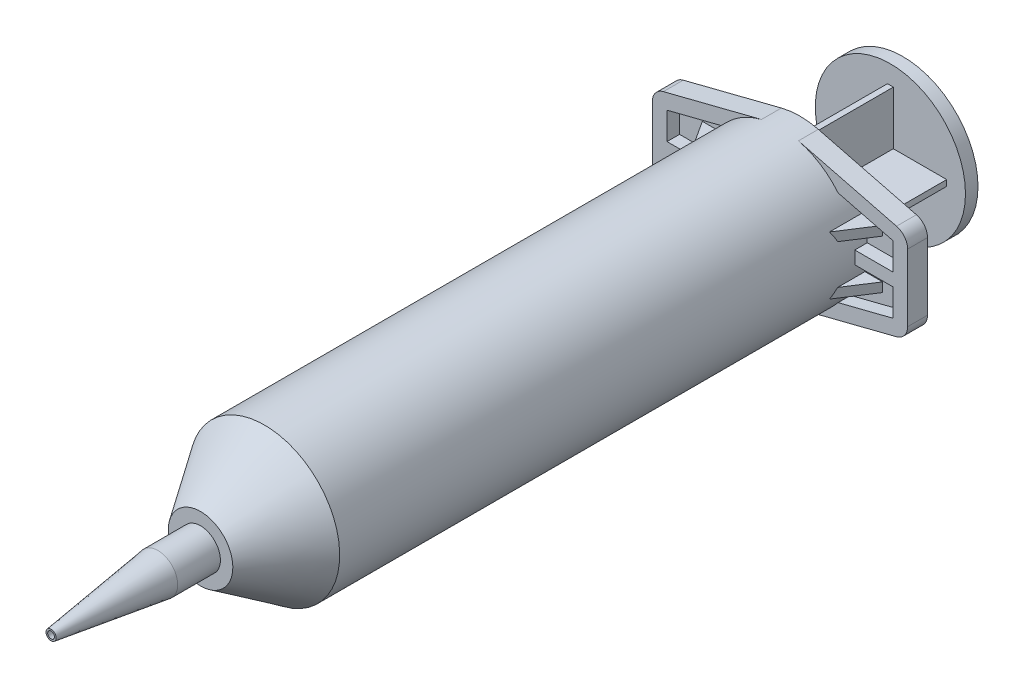
from build123d import *
from build123d.topology import SkipClean

# Parameters (mm, degrees)
BOSS_EXTRUDE1_START = 3.429
SKETCH3_R           = 11.43
BOSS_EXTRUDE1_DEPTH = 3.429
FILLET1_R           = 2.54
SKETCH5_R           = 12.954
BOSS_EXTRUDE2_DEPTH = 2.159
BOSS_EXTRUDE3_DEPTH = 96.8375
SKETCH7_R           = 10.287
BOSS_EXTRUDE4_DEPTH = 1.27
CUT_EXTRUDE1_START  = -2.159
CUT_EXTRUDE1_DEPTH  = 2.159
BOSS_EXTRUDE5_DEPTH = 5.0165
CUT_EXTRUDE2_DEPTH  = 131.416111398
CUT_EXTRUDE3_DEPTH  = 129.299644159


with BuildPart() as part:
    # Sketch2 → Revolve1 (revolve)
    with BuildSketch(Plane(origin=(0, 0, 0), x_dir=(0, 0, -1), z_dir=(1, 0, 0)), mode=Mode.PRIVATE) as revolve1_sk:
        Polygon((52.2605, 11.43), (-36.6395, 11.43), (-46.280429208, 4.987199723), (-46.280429208, 3.1369), (-55.0545, 3.1369), (-73.4695, 0.5842), (-73.4695, 0.8763), (-55.0545, 3.429), (-47.6885, 3.429), (-47.6885, 5.57022), (-36.6395, 12.954), (52.2605, 12.954), align=None)
    revolve(revolve1_sk.sketch.rotate(Axis((0, 0, 73.4695), (0, 0, -1)), 180), axis=Axis((0, 0, 73.4695), (0, 0, -1)))

    # Sketch3 → Boss-Extrude1 (add)
    with BuildSketch(Plane(origin=(0, 0, -52.2605), x_dir=(-1, 0, 0), z_dir=(0, 0, -1)).offset(BOSS_EXTRUDE1_START)):
        with BuildLine():
            Line((-3.188676923, 12.555415385), (-22.0218, 7.7724))
            Line((-22.0218, 7.7724), (-22.0218, -7.7724))
            Line((-22.0218, -7.7724), (-3.188676923, -12.555415385))
            ThreePointArc((-3.188676923, -12.555415385), (0, -12.954), (3.188676923, -12.555415385))
            Line((3.188676923, -12.555415385), (22.0218, -7.7724))
            Line((22.0218, -7.7724), (22.0218, 7.7724))
            Line((22.0218, 7.7724), (3.188676923, 12.555415385))
            ThreePointArc((3.188676923, 12.555415385), (0, 12.954), (-3.188676923, 12.555415385))
        make_face()
        with Locations(Location((0, 0, 0), (0, 0, 270))):
            Circle(SKETCH3_R, mode=Mode.SUBTRACT)
    extrude(amount=-BOSS_EXTRUDE1_DEPTH)

    # Fillet1
    fillet1_edges = [part.edges().sort_by_distance(p)[0] for p in [
        (22.0218, 7.7724, -53.975),
        (22.0218, -7.7724, -53.975),
        (-22.0218, -7.7724, -53.975),
        (-22.0218, 7.7724, -53.975),
    ]]
    fillet(fillet1_edges, radius=FILLET1_R)

    # Sketch12 → Cut-Extrude1 (cut)
    with BuildSketch(Plane.XY.offset(-52.2605).offset(CUT_EXTRUDE1_START)):
        with BuildLine():
            Line((19.4818, 5.796844444), (10.030595253, 8.197150412))
            ThreePointArc((10.030595253, 8.197150412), (12.004413847, 4.868281442), (12.90679325, 1.1049))
            Line((12.90679325, 1.1049), (19.4818, 1.1049))
            Line((19.4818, 1.1049), (19.4818, 5.796844444))
        make_face()
        with BuildLine():
            Line((19.4818, -5.796844444), (10.030595253, -8.197150412))
            ThreePointArc((10.030595253, -8.197150412), (12.004413847, -4.868281442), (12.90679325, -1.1049))
            Line((12.90679325, -1.1049), (19.4818, -1.1049))
            Line((19.4818, -1.1049), (19.4818, -5.796844444))
        make_face()
    cut_extrude1 = extrude(amount=CUT_EXTRUDE1_DEPTH, mode=Mode.SUBTRACT)

    # Sketch14 → Boss-Extrude5 (add, symmetric)
    with BuildSketch(Plane(origin=(0, 0, 0), x_dir=(1, 0, 0), z_dir=(0, 1, 0))):
        Polygon((11.43, 54.4195), (11.43, 48.0695), (15.5448, 54.4195), align=None)
    boss_extrude5 = extrude(amount=BOSS_EXTRUDE5_DEPTH, both=True)

    # Sketch15 → Cut-Extrude2 (cut, through all)
    with BuildSketch(Plane.XY.offset(-54.4195)):
        with BuildLine():
            Line((15.5448, 3.4163), (12.495399566, 3.4163))
            ThreePointArc((12.495399566, 3.4163), (12.753567832, 2.269939107), (12.90679325, 1.1049))
            Line((12.90679325, 1.1049), (14.145768, 1.1049))
            Line((14.145768, 1.1049), (15.5448, 1.1049))
            Line((15.5448, 1.1049), (15.5448, 3.4163))
        make_face()
        with BuildLine():
            Line((15.5448, -3.4163), (12.495399566, -3.4163))
            ThreePointArc((12.495399566, -3.4163), (12.753567832, -2.269939107), (12.90679325, -1.1049))
            Line((12.90679325, -1.1049), (14.145768, -1.1049))
            Line((14.145768, -1.1049), (15.5448, -1.1049))
            Line((15.5448, -1.1049), (15.5448, -3.4163))
        make_face()
    cut_extrude2 = extrude(amount=CUT_EXTRUDE2_DEPTH, mode=Mode.SUBTRACT)

    # Sketch16 → Cut-Extrude3 (cut, through all)
    with BuildSketch(Plane.XY.offset(-52.2605)):
        with BuildLine():
            Line((14.145768, -1.1049), (12.90679325, -1.1049))
            ThreePointArc((12.90679325, -1.1049), (12.954, 0), (12.90679325, 1.1049))
            Line((12.90679325, 1.1049), (14.145768, 1.1049))
            Line((14.145768, 1.1049), (14.145768, -1.1049))
        make_face()
    cut_extrude3 = extrude(amount=CUT_EXTRUDE3_DEPTH, mode=Mode.SUBTRACT)

    # Mirror1: Cut-Extrude1, Boss-Extrude5, Cut-Extrude2, Cut-Extrude3 across plane
    with SkipClean():  # the faces are left unmerged after this step: merging them gives an invalid solid
        add(cut_extrude1.mirror(Plane(origin=(0, 0, 0), x_dir=(0, 0, 1), z_dir=(1, 0, 0))), mode=Mode.SUBTRACT)
        add(boss_extrude5.mirror(Plane(origin=(0, 0, 0), x_dir=(0, 0, 1), z_dir=(1, 0, 0))))
        add(cut_extrude2.mirror(Plane(origin=(0, 0, 0), x_dir=(0, 0, 1), z_dir=(1, 0, 0))), mode=Mode.SUBTRACT)
        add(cut_extrude3.mirror(Plane(origin=(0, 0, 0), x_dir=(0, 0, 1), z_dir=(1, 0, 0))), mode=Mode.SUBTRACT)


with BuildPart() as body_2:
    # Sketch5 → Boss-Extrude2 (new body)
    with BuildSketch(Plane.XY.offset(-73.4695)):
        Circle(SKETCH5_R)
    extrude(amount=BOSS_EXTRUDE2_DEPTH)

    # Sketch6 → Boss-Extrude3 (add)
    with BuildSketch(Plane.XY.offset(-71.3105)):
        Polygon((-0.508, 9.7155), (0.508, 9.7155), (0.508, 0.508), (9.7155, 0.508), (9.7155, -0.508), (0.508, -0.508), (0.508, -9.7155), (-0.508, -9.7155), (-0.508, -0.508), (-9.7155, -0.508), (-9.7155, 0.508), (-0.508, 0.508), align=None)
    extrude(amount=BOSS_EXTRUDE3_DEPTH)

    # Sketch7 → Boss-Extrude4 (add)
    with BuildSketch(Plane.XY.offset(25.527)):
        Circle(SKETCH7_R)
    extrude(amount=BOSS_EXTRUDE4_DEPTH)


with BuildPart() as body_3:
    # Sketch8 → Revolve2 (revolve)
    with BuildSketch(Plane(origin=(0, 0, 0), x_dir=(0, 0, -1), z_dir=(1, 0, 0)), mode=Mode.PRIVATE) as revolve2_sk:
        Polygon((-36.6395, 0), (-26.797, 0), (-26.797, 10.287), (-28.273375, 10.287), (-29.74975, 11.43), (-31.226125, 10.287), (-32.7025, 10.287), (-34.178875, 11.43), align=None)
    revolve(revolve2_sk.sketch.rotate(Axis((0, 0, 73.4695), (0, 0, -1)), 180), axis=Axis((0, 0, 73.4695), (0, 0, -1)))


solid = Compound([part.part, body_2.part, body_3.part])
